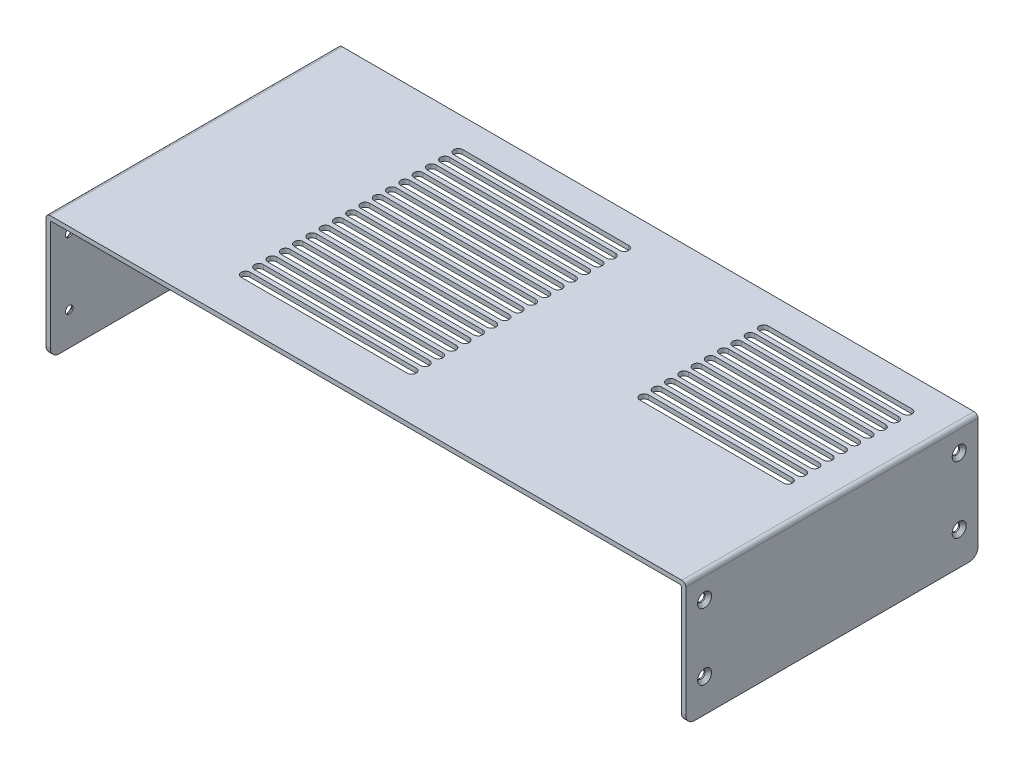
from build123d import *

# Parameters (mm, degrees)
BOSS_EXTRUDE1_DEPTH                             = 132
CSK_FOR_M3_FLAT_HEAD_MACHINE_SCREW1_D           = 3.4
CSK_FOR_M3_FLAT_HEAD_MACHINE_SCREW1_DEPTH       = 5
CSK_FOR_M3_FLAT_HEAD_MACHINE_SCREW1_CSINK_D     = 6.3
CSK_FOR_M3_FLAT_HEAD_MACHINE_SCREW1_CSINK_ANGLE = 90
CSK_FOR_M3_FLAT_HEAD_MACHINE_SCREW1_TIP         = 1.021463052
CSK_FOR_M3_FLAT_HEAD_MACHINE_SCREW2_D           = 3.4
CSK_FOR_M3_FLAT_HEAD_MACHINE_SCREW2_DEPTH       = 5
CSK_FOR_M3_FLAT_HEAD_MACHINE_SCREW2_CSINK_D     = 6.3
CSK_FOR_M3_FLAT_HEAD_MACHINE_SCREW2_CSINK_ANGLE = 90
CSK_FOR_M3_FLAT_HEAD_MACHINE_SCREW2_TIP         = 1.021463052
CUT_EXTRUDE1_DEPTH                              = 5
LPATTERN1_COUNT                                 = 17
LPATTERN1_PITCH                                 = 6
CUT_EXTRUDE2_DEPTH                              = 200
LPATTERN2_COUNT                                 = 10
LPATTERN2_PITCH                                 = 6
FILLET1_R                                       = 4


with BuildPart() as part:
    # Sketch1 → Boss-Extrude1 (new body)
    with BuildSketch(Plane.XY):
        with BuildLine():
            Line((0, 0), (-2, 0))
            Line((-2, 0), (-2, 54.2))
            ThreePointArc((-2, 54.2), (-1.472792206, 55.472792206), (-0.2, 56))
            Line((-0.2, 56), (285.2, 56))
            ThreePointArc((285.2, 56), (286.472792206, 55.472792206), (287, 54.2))
            Line((287, 54.2), (287, 0))
            Line((287, 0), (285, 0))
            Line((285, 0), (285, 53.5))
            ThreePointArc((285, 53.5), (284.853553391, 53.853553391), (284.5, 54))
            Line((284.5, 54), (0.5, 54))
            ThreePointArc((0.5, 54), (0.146446609, 53.853553391), (0, 53.5))
            Line((0, 53.5), (0, 0))
        make_face()
    extrude(amount=BOSS_EXTRUDE1_DEPTH)

    # CSK for M3 Flat Head Machine Screw1
    with Locations(Plane.ZY.offset(2)):
        with Locations((8.5, 45), (8.5, 15), (123.5, 45), (123.5, 15)):
            CounterSinkHole(CSK_FOR_M3_FLAT_HEAD_MACHINE_SCREW1_D / 2, CSK_FOR_M3_FLAT_HEAD_MACHINE_SCREW1_CSINK_D / 2, depth=CSK_FOR_M3_FLAT_HEAD_MACHINE_SCREW1_DEPTH, counter_sink_angle=CSK_FOR_M3_FLAT_HEAD_MACHINE_SCREW1_CSINK_ANGLE)
            with Locations((0, 0, -(CSK_FOR_M3_FLAT_HEAD_MACHINE_SCREW1_DEPTH + CSK_FOR_M3_FLAT_HEAD_MACHINE_SCREW1_TIP / 2))):  # 118° drill point
                Cone(0, CSK_FOR_M3_FLAT_HEAD_MACHINE_SCREW1_D / 2, CSK_FOR_M3_FLAT_HEAD_MACHINE_SCREW1_TIP, mode=Mode.SUBTRACT)

    # CSK for M3 Flat Head Machine Screw2
    with Locations(Plane(origin=(287, 0, 0), x_dir=(0, 0, -1), z_dir=(1, 0, 0))):
        with Locations((-123.5, 45), (-123.5, 15), (-8.5, 45), (-8.5, 15)):
            CounterSinkHole(CSK_FOR_M3_FLAT_HEAD_MACHINE_SCREW2_D / 2, CSK_FOR_M3_FLAT_HEAD_MACHINE_SCREW2_CSINK_D / 2, depth=CSK_FOR_M3_FLAT_HEAD_MACHINE_SCREW2_DEPTH, counter_sink_angle=CSK_FOR_M3_FLAT_HEAD_MACHINE_SCREW2_CSINK_ANGLE)
            with Locations((0, 0, -(CSK_FOR_M3_FLAT_HEAD_MACHINE_SCREW2_DEPTH + CSK_FOR_M3_FLAT_HEAD_MACHINE_SCREW2_TIP / 2))):  # 118° drill point
                Cone(0, CSK_FOR_M3_FLAT_HEAD_MACHINE_SCREW2_D / 2, CSK_FOR_M3_FLAT_HEAD_MACHINE_SCREW2_TIP, mode=Mode.SUBTRACT)

    # Sketch6 → Cut-Extrude1 (cut)
    with BuildSketch(Plane(origin=(0, 56, 0), x_dir=(1, 0, 0), z_dir=(0, 1, 0))):
        with BuildLine():
            Line((67.2, -13), (142.2, -13))
            ThreePointArc((142.2, -13), (144.2, -15), (142.2, -17))
            Line((142.2, -17), (67.2, -17))
            ThreePointArc((67.2, -17), (65.2, -15), (67.2, -13))
        make_face()
    cut_extrude1 = extrude(amount=-CUT_EXTRUDE1_DEPTH, mode=Mode.SUBTRACT)

    # LPattern1: Cut-Extrude1 ×17
    with Locations(*[(0, 0, i * LPATTERN1_PITCH) for i in range(1, LPATTERN1_COUNT)]):
        add(cut_extrude1, mode=Mode.SUBTRACT)

    # Sketch7 → Cut-Extrude2 (cut)
    with BuildSketch(Plane(origin=(0, 56, 0), x_dir=(1, 0, 0), z_dir=(0, 1, 0))):
        with BuildLine():
            Line((205.2, -13), (270.2, -13))
            ThreePointArc((270.2, -13), (272.2, -15), (270.2, -17))
            Line((270.2, -17), (205.2, -17))
            ThreePointArc((205.2, -17), (203.2, -15), (205.2, -13))
        make_face()
    cut_extrude2 = extrude(amount=-CUT_EXTRUDE2_DEPTH, mode=Mode.SUBTRACT)

    # LPattern2: Cut-Extrude2 ×10
    with Locations(*[(0, 0, i * LPATTERN2_PITCH) for i in range(1, LPATTERN2_COUNT)]):
        add(cut_extrude2, mode=Mode.SUBTRACT)

    # Fillet1
    fillet1_edges = [part.edges().sort_by_distance(p)[0] for p in [
        (-1, 0, 0),
        (286, 0, 0),
        (286, 0, 132),
        (-1, 0, 132),
    ]]
    fillet(fillet1_edges, radius=FILLET1_R)


solid = part.part
